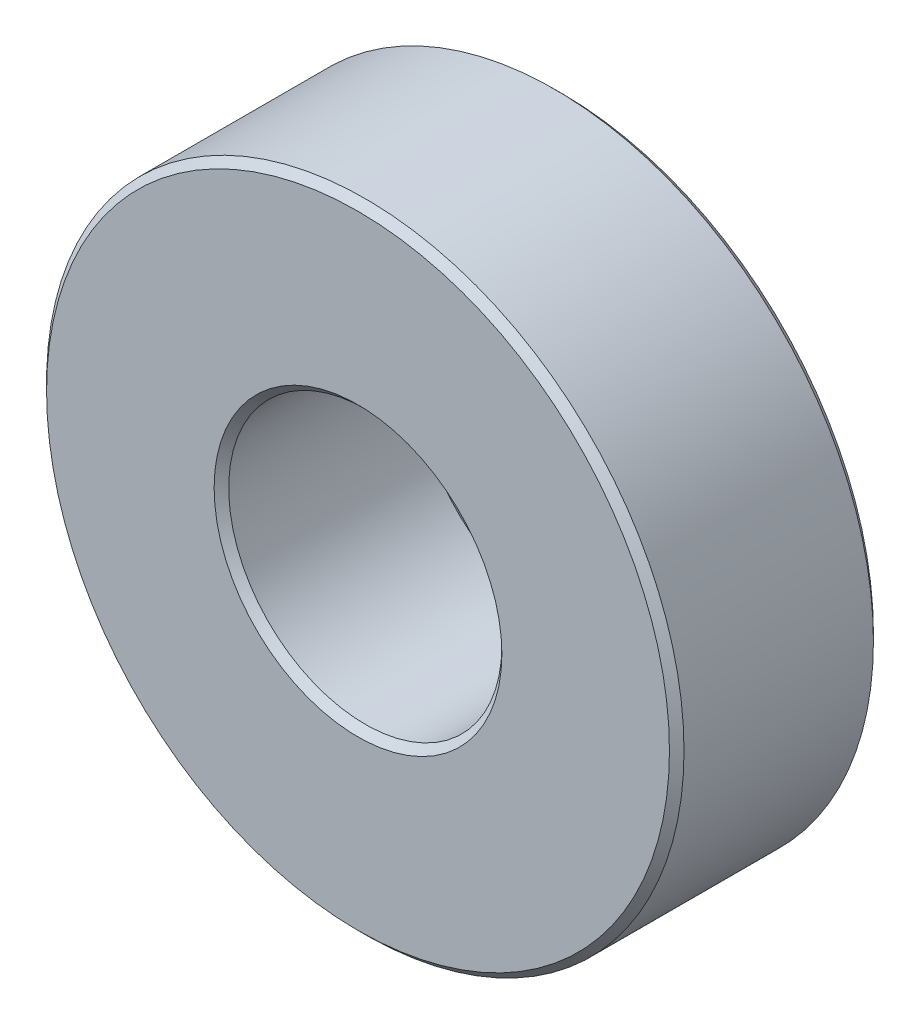
from build123d import *

# Parameters (mm, degrees)
SKETCH1_W     = 6.35
SKETCH1_H     = 7.112
CHAMFER1_SIZE = 0.254


with BuildPart() as part:
    # Sketch1 → Revolve1 (revolve)
    with BuildSketch(Plane(origin=(0, 0, 0), x_dir=(1, 0, 0), z_dir=(0, 1, 0))):
        with Locations((7.9375, -3.556)):
            Rectangle(SKETCH1_W, SKETCH1_H)
    revolve(axis=Axis((0, 0, 0), (0, 0, 1)))

    # Chamfer1
    chamfer1_edges = [part.edges().sort_by_distance(p)[0] for p in [
        (-11.1125, 0, 0),
        (-11.1125, 0, 7.112),
        (-4.7625, 0, 7.112),
        (-4.7625, 0, 0),
    ]]
    chamfer(chamfer1_edges, length=CHAMFER1_SIZE)


solid = part.part
